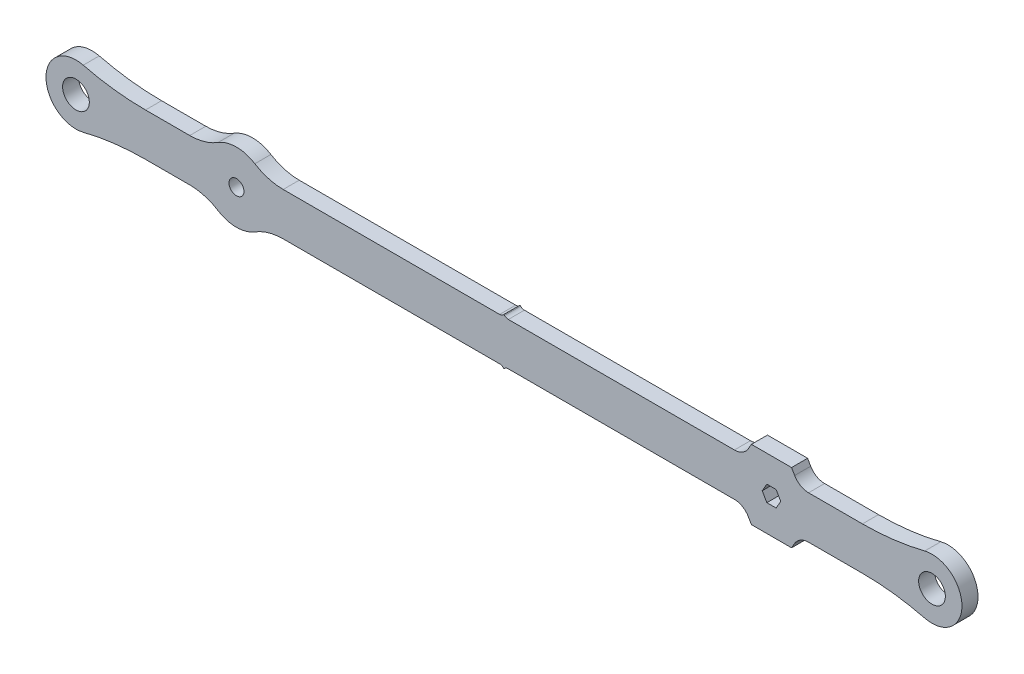
from build123d import *

# Parameters (mm, degrees)
SKETCH1_R           = 1.5
BOSS_EXTRUDE1_DEPTH = 3
SKETCH3_W           = 1.998076211
SKETCH3_H           = 3
FILLET1_R           = 48
BOSS_EXTRUDE3_DEPTH = 3
SKETCH8_R           = 1.4
CUT_EXTRUDE3_DEPTH  = 4
SKETCH9_R           = 4
BOSS_EXTRUDE6_DEPTH = 3


with BuildPart() as part:
    # Sketch1 → Boss-Extrude1 (new body)
    with BuildSketch(Plane.XY):
        with BuildLine():
            Line((-76.080816412, -4), (76.080816412, -4))
            ThreePointArc((76.080816412, -4), (85.6, 0), (76.080816412, 4))
            Line((76.080816412, 4), (-76.080816412, 4))
            ThreePointArc((-76.080816412, 4), (-85.6, 0), (-76.080816412, -4))
        make_face()
        with Locations((-80, 0)):
            Circle(SKETCH1_R, mode=Mode.SUBTRACT)
        with Locations((80, 0)):
            Circle(SKETCH1_R, mode=Mode.SUBTRACT)
    extrude(amount=BOSS_EXTRUDE1_DEPTH)

    # Sketch3 → Cut-Revolve1 (revolve, cut)
    with BuildSketch(Plane(origin=(0, 0, 0), x_dir=(1, 0, 0), z_dir=(0, 1, 0))):
        with Locations((81.499038106, -1.5)):
            Rectangle(SKETCH3_W, SKETCH3_H)
    cut_revolve1 = revolve(axis=Axis((80, 0, 0), (0, 0, 1)), mode=Mode.SUBTRACT)

    # Mirror1: Cut-Revolve1 across plane
    add(cut_revolve1.mirror(Plane(origin=(0, 0, 0), x_dir=(0, 0, 1), z_dir=(1, 0, 0))), mode=Mode.SUBTRACT)

    # Fillet1
    fillet1_edges = [part.edges().sort_by_distance(p)[0] for p in [
        (76.080816412, -4, 1.5),
        (-76.080816412, -4, 1.5),
        (-76.080816412, 4, 1.5),
        (76.080816412, 4, 1.5),
    ]]
    fillet(fillet1_edges, radius=FILLET1_R)

    # Sketch4 → Boss-Extrude3 (add, through all)
    with BuildSketch(Plane.XY.offset(3)):
        with BuildLine():
            Line((0, -4.4), (0.107106781, -4.292893219))
            ThreePointArc((0.107106781, -4.292893219), (0.43153013, -4.076120467), (0.814213562, -4))
            Line((0.814213562, -4), (4.4, -4))
            Line((4.4, -4), (4.4, 4))
            Line((4.4, 4), (0.814213562, 4))
            ThreePointArc((0.814213562, 4), (0.43153013, 4.076120467), (0.107106781, 4.292893219))
            Line((0.107106781, 4.292893219), (0, 4.4))
            Line((0, 4.4), (-0.107106781, 4.292893219))
            ThreePointArc((-0.107106781, 4.292893219), (-0.43153013, 4.076120467), (-0.814213562, 4))
            Line((-0.814213562, 4), (-4.4, 4))
            Line((-4.4, 4), (-4.4, -4))
            Line((-4.4, -4), (-0.814213562, -4))
            ThreePointArc((-0.814213562, -4), (-0.43153013, -4.076120467), (-0.107106781, -4.292893219))
            Line((-0.107106781, -4.292893219), (0, -4.4))
        make_face()
    extrude(amount=-BOSS_EXTRUDE3_DEPTH)

    # Sketch8 → Cut-Extrude3 (cut, through all)
    with BuildSketch(Plane.XY.offset(3)):
        with Locations((-50, 0)):
            Circle(SKETCH8_R)
        Polygon((51.732050808, 0), (50.866025404, 1.5), (49.133974596, 1.5), (48.267949192, 0), (49.133974596, -1.5), (50.866025404, -1.5), align=None)
    extrude(amount=-CUT_EXTRUDE3_DEPTH, mode=Mode.SUBTRACT)

    # Sketch9 → Boss-Extrude6 (add, through all)
    with BuildSketch(Plane.XY.offset(3)):
        with BuildLine():
            Line((38, -4), (43.07179677, -4))
            ThreePointArc((43.07179677, -4), (44.57179677, -4.401923789), (45.669872981, -5.5))
            Line((45.669872981, -5.5), (46.24722325, -6.5))
            Line((46.24722325, -6.5), (53.75277675, -6.5))
            Line((53.75277675, -6.5), (54.330127019, -5.5))
            ThreePointArc((54.330127019, -5.5), (55.42820323, -4.401923789), (56.92820323, -4))
            Line((56.92820323, -4), (62, -4))
            Line((62, -4), (62, 4))
            Line((62, 4), (56.92820323, 4))
            ThreePointArc((56.92820323, 4), (55.42820323, 4.401923789), (54.330127019, 5.5))
            Line((54.330127019, 5.5), (53.75277675, 6.5))
            Line((53.75277675, 6.5), (46.24722325, 6.5))
            Line((46.24722325, 6.5), (45.669872981, 5.5))
            ThreePointArc((45.669872981, 5.5), (44.57179677, 4.401923789), (43.07179677, 4))
            Line((43.07179677, 4), (38, 4))
            Line((38, 4), (38, -4))
        make_face()
        with Locations((50, 0)):
            Circle(SKETCH9_R, mode=Mode.SUBTRACT)
        with BuildLine():
            Line((-58.732124598, -4), (-62, -4))
            Line((-62, -4), (-62, 4))
            Line((-62, 4), (-58.732124598, 4))
            ThreePointArc((-58.732124598, 4), (-55.979715185, 4.386247225), (-53.439927872, 5.515151515))
            ThreePointArc((-53.439927872, 5.515151515), (-50, 6.5), (-46.560072128, 5.515151515))
            ThreePointArc((-46.560072128, 5.515151515), (-44.020284815, 4.386247225), (-41.267875402, 4))
            Line((-41.267875402, 4), (-38, 4))
            Line((-38, 4), (-38, -4))
            Line((-38, -4), (-41.267875402, -4))
            ThreePointArc((-41.267875402, -4), (-44.020284815, -4.386247225), (-46.560072128, -5.515151515))
            ThreePointArc((-46.560072128, -5.515151515), (-50, -6.5), (-53.439927872, -5.515151515))
            ThreePointArc((-53.439927872, -5.515151515), (-55.979715185, -4.386247225), (-58.732124598, -4))
        make_face()
        with Locations((-50, 0)):
            Circle(SKETCH9_R, mode=Mode.SUBTRACT)
    extrude(amount=-BOSS_EXTRUDE6_DEPTH)


solid = part.part
